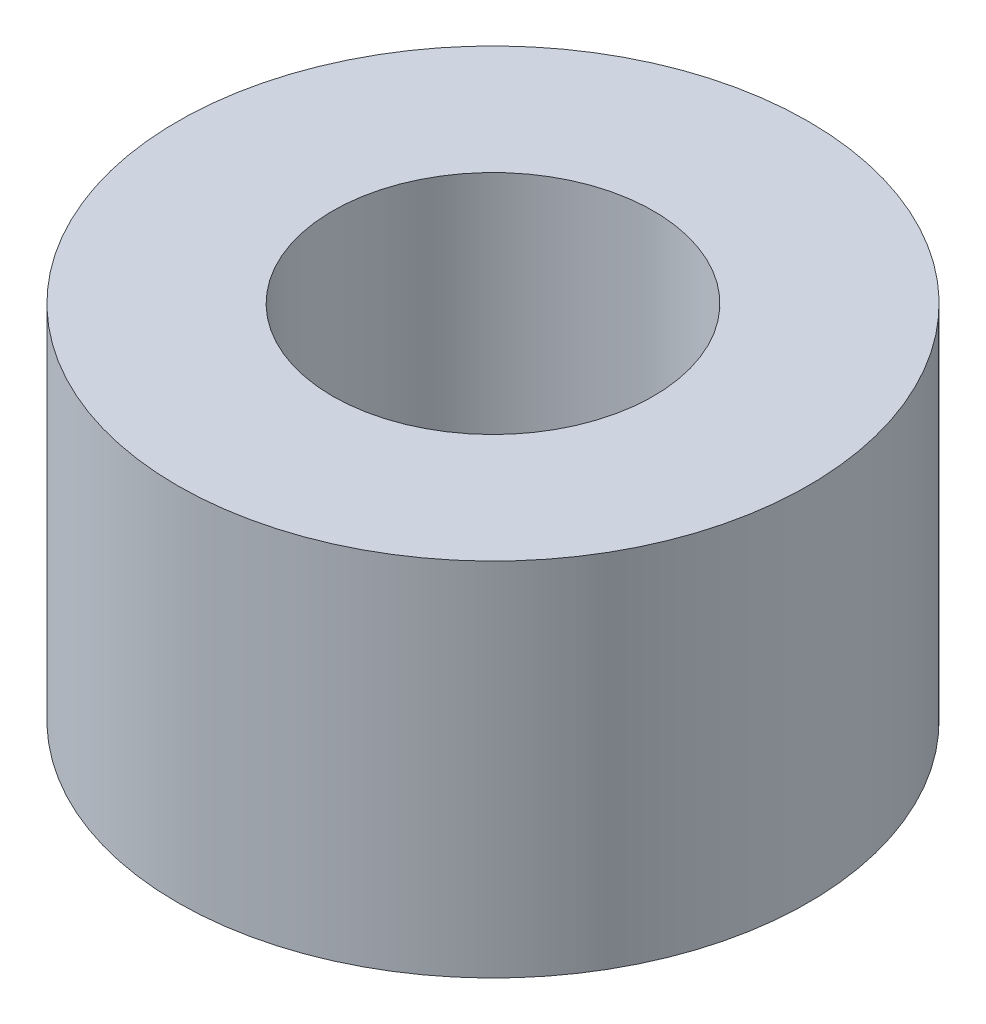
from build123d import *

# Parameters (mm, degrees)
SKETCH1_R           = 6.24205
BOSS_EXTRUDE1_DEPTH = 7.14502
SKETCH2_R           = 3.175
CUT_EXTRUDE1_DEPTH  = 8.14502


with BuildPart() as part:
    # Sketch1 → Boss-Extrude1 (new body)
    with BuildSketch(Plane(origin=(0, 0, 0), x_dir=(1, 0, 0), z_dir=(0, 1, 0))):
        Circle(SKETCH1_R)
    extrude(amount=BOSS_EXTRUDE1_DEPTH)

    # Sketch2 → Cut-Extrude1 (cut, through all)
    with BuildSketch(Plane(origin=(0, 0, 0), x_dir=(1, 0, 0), z_dir=(0, 1, 0))):
        Circle(SKETCH2_R)
    extrude(amount=CUT_EXTRUDE1_DEPTH, mode=Mode.SUBTRACT)


solid = part.part
